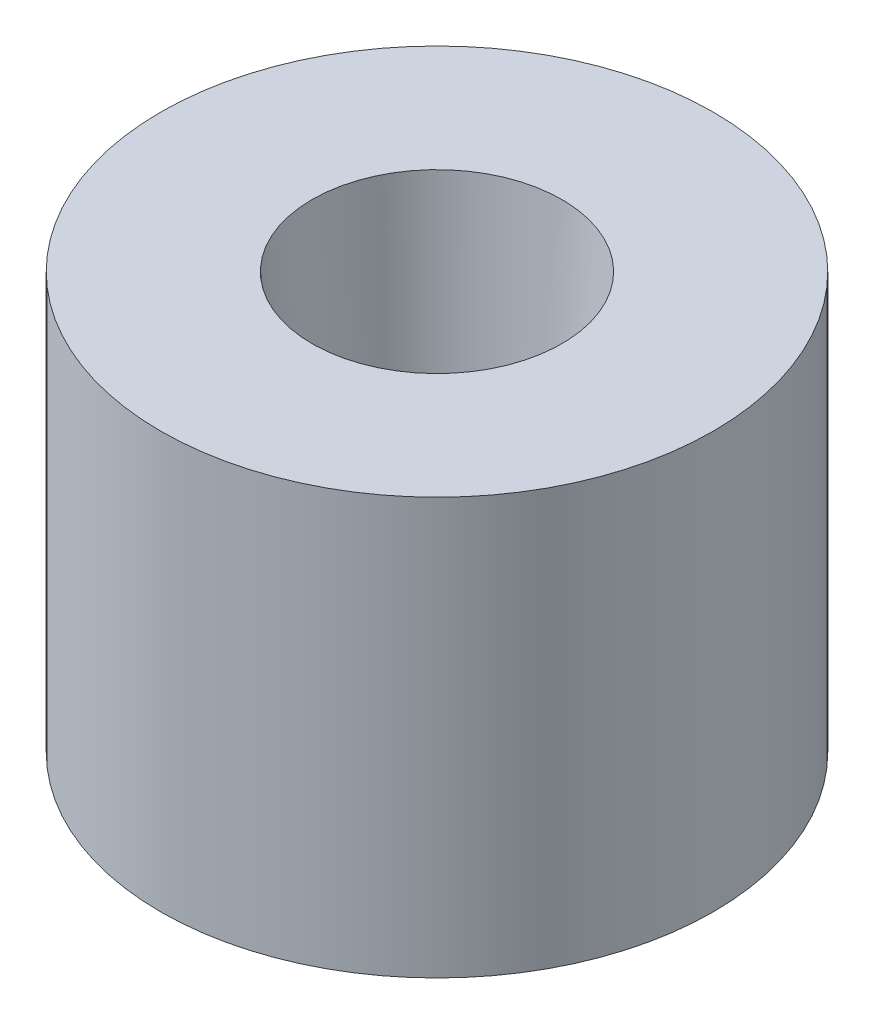
from build123d import *


with BuildPart() as part:
    # Sketch1 → Revolve1 (revolve)
    with BuildSketch(Plane.XY):
        Polygon((0, 0), (-3.65, 0), (-3.65, 5.5), (-1.65, 5.5), (-1.43, 1.5), (0, 1.5), align=None)
    revolve(axis=Axis((0, 1.5, 0), (0, -1, 0)))


solid = part.part
